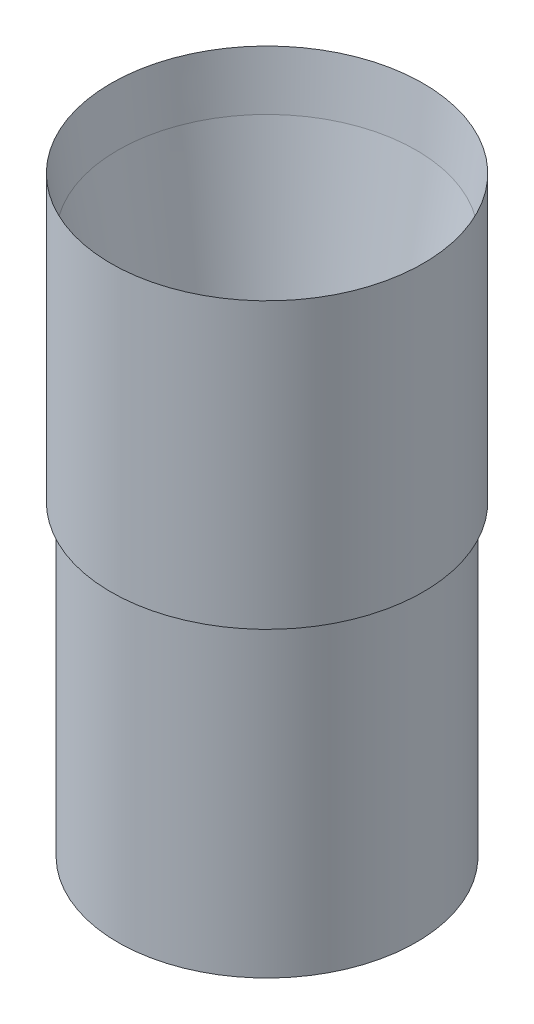
from build123d import *


with BuildPart() as part:
    # Sketch1 → Revolve1 (revolve)
    with BuildSketch(Plane.XY):
        Polygon((2.032, 0), (0, 0), (0, 101.6), (-2.286, 101.6), (-2.286, 195.80606), (0, 177.8), (8.95741062, 127), (8.95741062, 101.6), (2.032, 101.6), align=None)
    revolve(axis=Axis((49.3903, 245.641517485, 0), (0, -1, 0)))


solid = part.part
